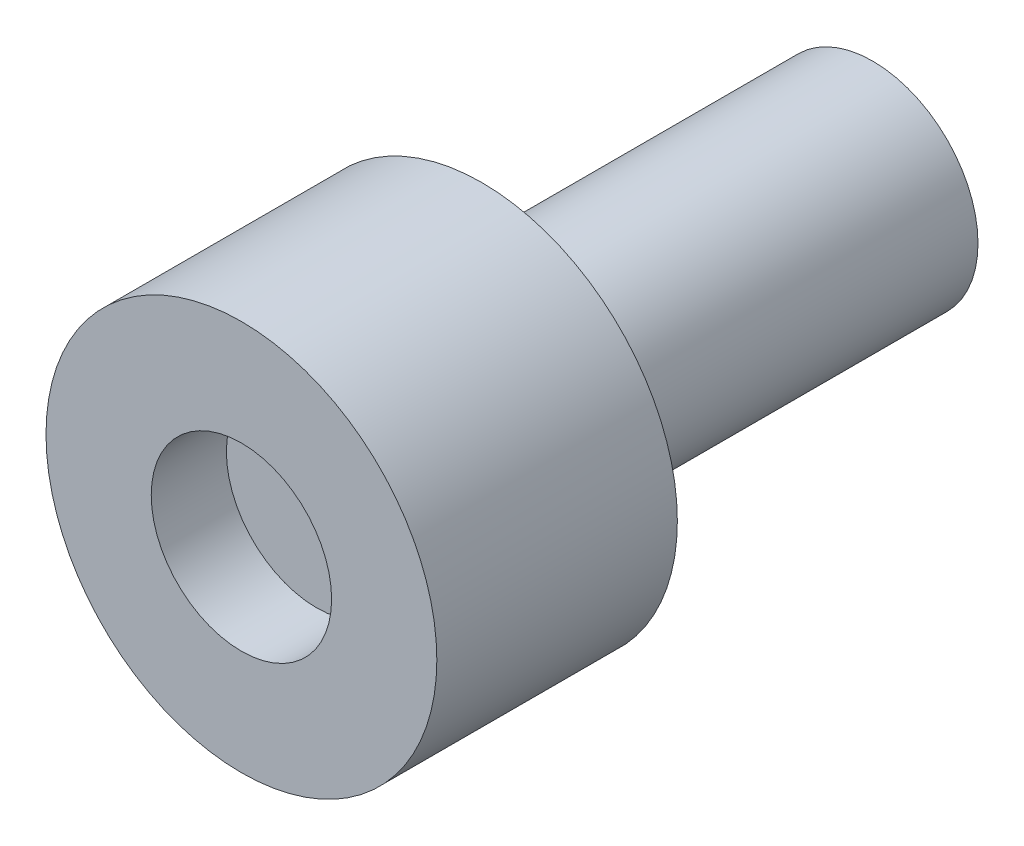
from build123d import *


with BuildPart() as part:
    # Sketch1 → Revolve1 (revolve)
    with BuildSketch(Plane.XZ):
        Polygon((3, 5.5), (0, 5.5), (0, -13), (3.5, -13), (3.5, 0), (6.5, 0), (6.5, 8), (3, 8), align=None)
    revolve(axis=Axis((0, 0, 8), (0, 0, -1)))


solid = part.part
